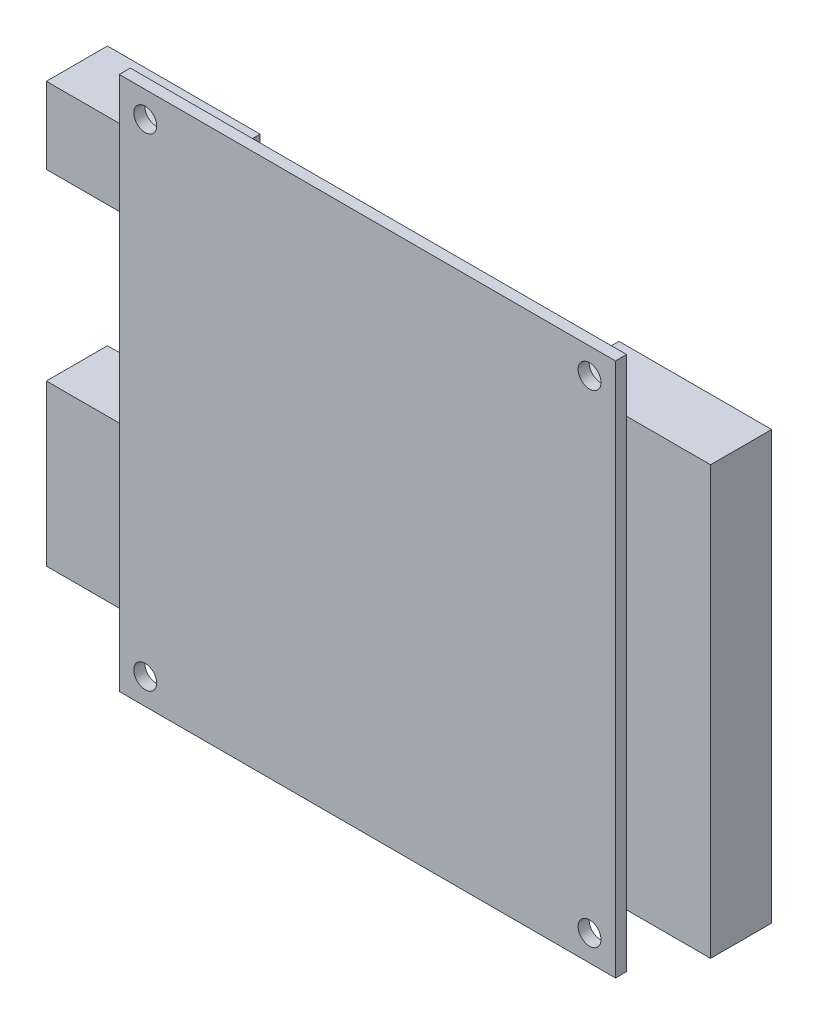
from build123d import *

# Parameters (mm, degrees)
SKETCH_1_W               = 65
SKETCH_1_H               = 70
EXTRUDE_1_DEPTH          = 1.45
SKETCH_2_R               = 1.5
CUT_EXTRUDE_1_DEPTH      = 2.45
MIRROR_2_COPY_1_SKETCH_R = 1.5
MIRROR_2_COPY_1_DEPTH    = 2.45
SKETCH_3_W               = 10
SKETCH_3_H               = 56
EXTRUDE_3_DEPTH          = 8
SKETCH_4_W               = 10
SKETCH_4_H               = 10
EXTRUDE_4_DEPTH          = 8
SKETCH_5_W               = 10
SKETCH_5_H               = 22
EXTRUDE_5_DEPTH          = 8
SKETCH_6_W               = 10
SKETCH_6_H               = 21
EXTRUDE_6_DEPTH          = 8
SKETCH_7_W               = 8
SKETCH_7_H               = 21
EXTRUDE_7_DEPTH          = 10
SKETCH_9_W               = 8
SKETCH_9_H               = 10
EXTRUDE_9_DEPTH          = 10
SKETCH_10_W              = 8
SKETCH_10_H              = 56
EXTRUDE_10_DEPTH         = 10


with BuildPart() as part:
    # 草圖1 → 填料-伸長1 (new body)
    with BuildSketch(Plane.XY):
        Rectangle(SKETCH_1_W, SKETCH_1_H)
    extrude(amount=EXTRUDE_1_DEPTH)

    # 草圖2 → 除料-伸長1 (cut, through all)
    with BuildSketch(Plane(origin=(0, 0, 0), x_dir=(-1, 0, 0), z_dir=(0, 0, -1))):
        with Locations((29.1, 31.6)):
            Circle(SKETCH_2_R)
    cut_extrude_1 = extrude(amount=-CUT_EXTRUDE_1_DEPTH, mode=Mode.SUBTRACT)

    # 鏡射1: 除料-伸長1 across plane
    add(cut_extrude_1.mirror(Plane(origin=(0, 0, 0), x_dir=(0, 0, 1), z_dir=(1, 0, 0))), mode=Mode.SUBTRACT)

    # 鏡射2: 除料-伸長1 across plane
    add(cut_extrude_1.mirror(Plane.ZX), mode=Mode.SUBTRACT)

    # 鏡射2 copy 1 sketch → 鏡射2 copy 1 (cut, through all)
    with BuildSketch(Plane(origin=(0, 0, 0), x_dir=(1, 0, 0), z_dir=(0, 0, -1))):
        with Locations((29.1, 31.6)):
            Circle(MIRROR_2_COPY_1_SKETCH_R)
    extrude(amount=-MIRROR_2_COPY_1_DEPTH, mode=Mode.SUBTRACT)

    # 草圖3 → 填料-伸長3 (add)
    with BuildSketch(Plane(origin=(0, 0, 0), x_dir=(-1, 0, 0), z_dir=(0, 0, -1))):
        with Locations((-28.5, 0)):
            Rectangle(SKETCH_3_W, SKETCH_3_H)
    extrude(amount=EXTRUDE_3_DEPTH)

    # 草圖4 → 填料-伸長4 (add)
    with BuildSketch(Plane(origin=(0, 0, 0), x_dir=(-1, 0, 0), z_dir=(0, 0, -1))):
        with Locations((28.5, 23)):
            Rectangle(SKETCH_4_W, SKETCH_4_H)
    extrude(amount=EXTRUDE_4_DEPTH)

    # 草圖5 → 填料-伸長5 (add)
    with BuildSketch(Plane(origin=(0, 0, 0), x_dir=(-1, 0, 0), z_dir=(0, 0, -1))):
        with Locations((28.5, 6)):
            Rectangle(SKETCH_5_W, SKETCH_5_H)
    extrude(amount=EXTRUDE_5_DEPTH)

    # 草圖6 → 填料-伸長6 (add)
    with BuildSketch(Plane(origin=(0, 0, 0), x_dir=(-1, 0, 0), z_dir=(0, 0, -1))):
        with Locations((28.5, -16.5)):
            Rectangle(SKETCH_6_W, SKETCH_6_H)
    extrude(amount=EXTRUDE_6_DEPTH)

    # 草圖7 → 填料-伸長7 (add)
    with BuildSketch(Plane.ZY.offset(33.5)):
        with Locations((-4, -16.5)):
            Rectangle(SKETCH_7_W, SKETCH_7_H)
    extrude(amount=EXTRUDE_7_DEPTH)

    # 草圖9 → 填料-伸長9 (add)
    with BuildSketch(Plane.ZY.offset(33.5)):
        with Locations((-4, 23)):
            Rectangle(SKETCH_9_W, SKETCH_9_H)
    extrude(amount=EXTRUDE_9_DEPTH)

    # 草圖10 → 填料-伸長10 (add)
    with BuildSketch(Plane(origin=(33.5, 0, 0), x_dir=(0, 0, -1), z_dir=(1, 0, 0))):
        with Locations((4, 0)):
            Rectangle(SKETCH_10_W, SKETCH_10_H)
    extrude(amount=EXTRUDE_10_DEPTH)


solid = part.part
